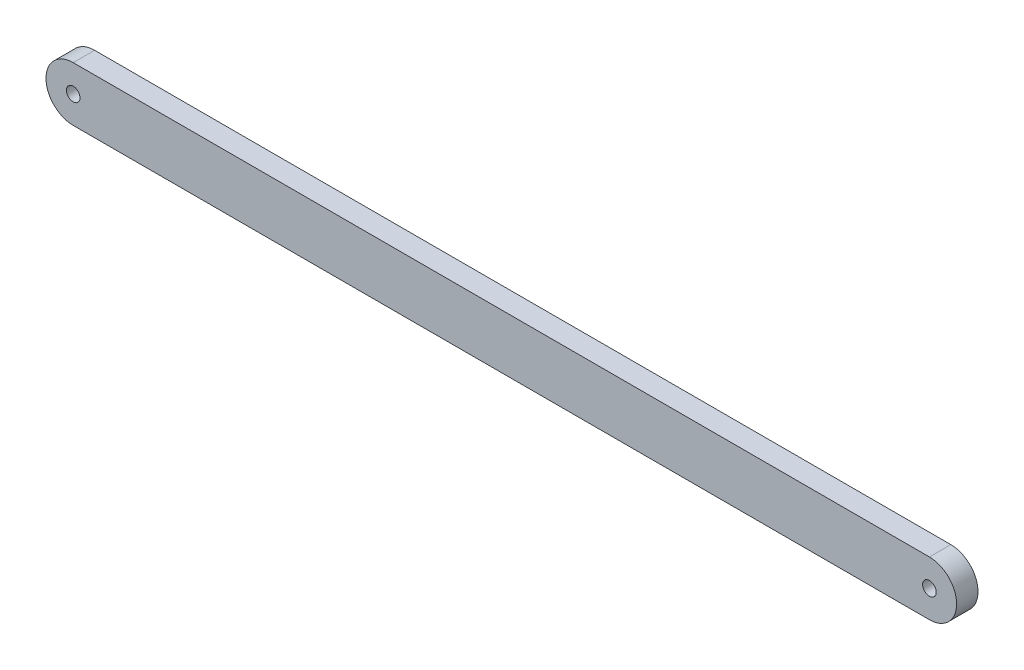
from build123d import *

# Parameters (mm, degrees)
SKETCH1_R           = 3.175
BOSS_EXTRUDE1_DEPTH = 10


with BuildPart() as part:
    # Sketch1 → Boss-Extrude1 (new body)
    with BuildSketch(Plane.XY):
        with BuildLine():
            Line((0, 12.7), (400, 12.7))
            ThreePointArc((400, 12.7), (412.7, 0), (400, -12.7))
            Line((400, -12.7), (0, -12.7))
            ThreePointArc((0, -12.7), (-12.7, 0), (0, 12.7))
        make_face()
        Circle(SKETCH1_R, mode=Mode.SUBTRACT)
        with Locations((400, 0)):
            Circle(SKETCH1_R, mode=Mode.SUBTRACT)
    extrude(amount=BOSS_EXTRUDE1_DEPTH)


solid = part.part
